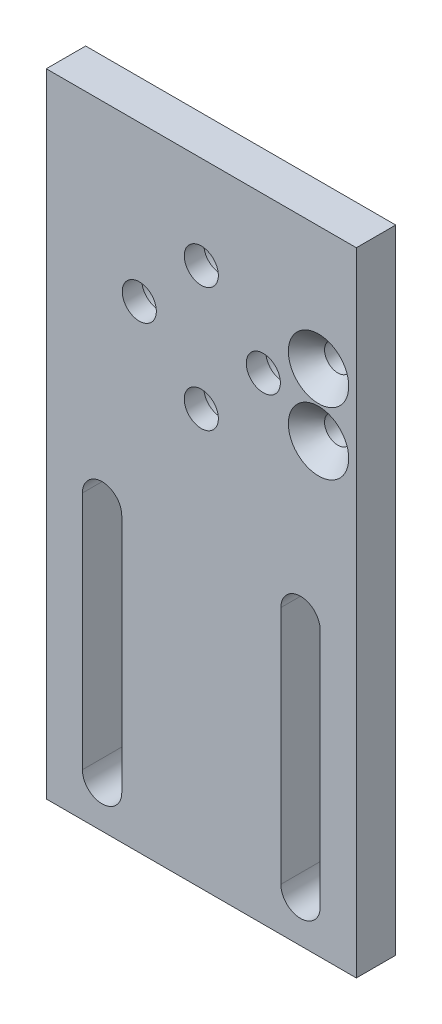
from build123d import *

# Parameters (mm, degrees)
BOSS_EXTRUDE1_DEPTH                            = 6.35
CSK_FOR_6_FLAT_HEAD_MACHINE_SCREW2_D           = 4.3053
CSK_FOR_6_FLAT_HEAD_MACHINE_SCREW2_CSINK_D     = 9.7361756
CSK_FOR_6_FLAT_HEAD_MACHINE_SCREW2_CSINK_ANGLE = 82
CBORE_FOR_M5_SHCS1_D                           = 5.5
CBORE_FOR_M5_SHCS1_CBORE_D                     = 10
CBORE_FOR_M5_SHCS1_CBORE_DEPTH                 = 3.2


with BuildPart() as part:
    # Sketch1 → Boss-Extrude1 (new body)
    with BuildSketch(Plane.XY):
        Polygon((25, -76.9874), (25, 25), (-25, 25), (-25, -76.9874), (0, -76.9874), align=None)
        with BuildLine():
            ThreePointArc((-19.177, -31.341450548), (-16.002, -28.166450548), (-12.827, -31.341450548))
            Line((-12.827, -31.341450548), (-12.827, -69.9897))
            ThreePointArc((-12.827, -69.9897), (-16.002, -73.1647), (-19.177, -69.9897))
            Line((-19.177, -69.9897), (-19.177, -31.341450548))
        make_face(mode=Mode.SUBTRACT)
        with BuildLine():
            ThreePointArc((12.827, -31.341450548), (16.002, -28.166450548), (19.177, -31.341450548))
            Line((19.177, -31.341450548), (19.177, -69.9897))
            ThreePointArc((19.177, -69.9897), (16.002, -73.1647), (12.827, -69.9897))
            Line((12.827, -69.9897), (12.827, -31.341450548))
        make_face(mode=Mode.SUBTRACT)
    extrude(amount=BOSS_EXTRUDE1_DEPTH)

    # CSK for #6 Flat Head Machine Screw2 (through all)
    with Locations(Plane.XY.offset(6.35)):
        with Locations((18.904, 5.04825), (18.904, -5.04825)):
            CounterSinkHole(CSK_FOR_6_FLAT_HEAD_MACHINE_SCREW2_D / 2, CSK_FOR_6_FLAT_HEAD_MACHINE_SCREW2_CSINK_D / 2, counter_sink_angle=CSK_FOR_6_FLAT_HEAD_MACHINE_SCREW2_CSINK_ANGLE)

    # CBORE for M5 SHCS1 (through all)
    with Locations(Plane(origin=(0, 0, 0), x_dir=(-1, 0, 0), z_dir=(0, 0, -1))):
        with Locations((0, 10), (-10, 0), (0, -10), (10, 0)):
            CounterBoreHole(CBORE_FOR_M5_SHCS1_D / 2, CBORE_FOR_M5_SHCS1_CBORE_D / 2, CBORE_FOR_M5_SHCS1_CBORE_DEPTH)


solid = part.part
